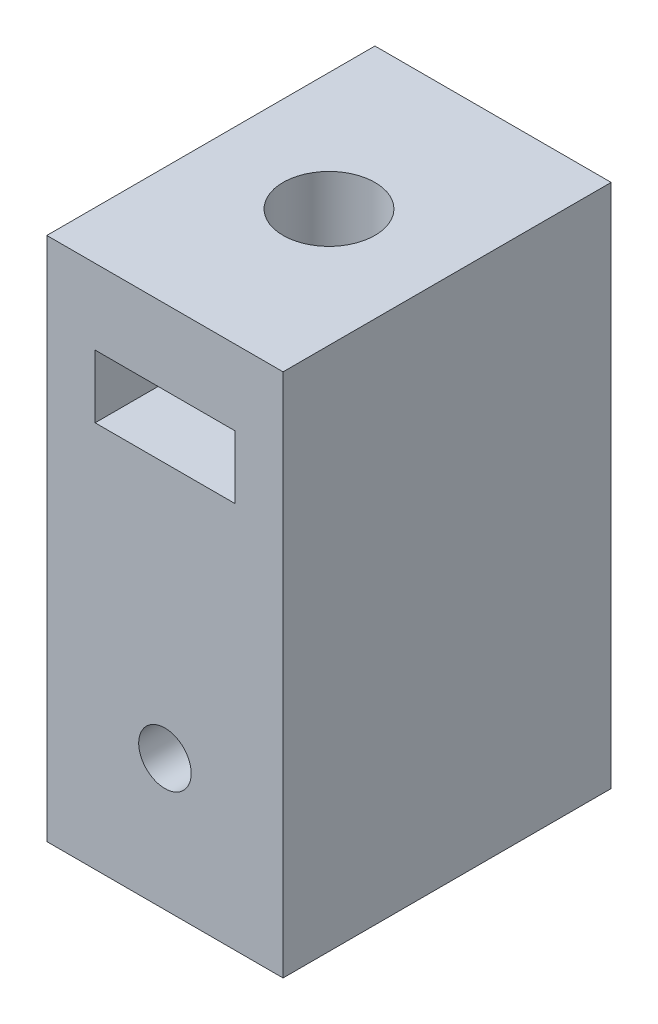
from build123d import *

# Parameters (mm, degrees)
SKETCH1_W           = 9
SKETCH1_H           = 12.5
BOSS_EXTRUDE1_DEPTH = 20
SKETCH2_R           = 1
CUT_EXTRUDE1_DEPTH  = 13.5
SKETCH3_W           = 5.32
SKETCH3_H           = 2.4
CUT_EXTRUDE2_DEPTH  = 13.5
SKETCH4_R           = 1.75
CUT_EXTRUDE3_DEPTH  = 13


with BuildPart() as part:
    # Sketch1 → Boss-Extrude1 (new body)
    with BuildSketch(Plane(origin=(0, 0, 0), x_dir=(1, 0, 0), z_dir=(0, 1, 0))):
        Rectangle(SKETCH1_W, SKETCH1_H)
    extrude(amount=BOSS_EXTRUDE1_DEPTH)

    # Sketch2 → Cut-Extrude1 (cut, through all)
    with BuildSketch(Plane.XY.offset(6.25)):
        with Locations((0, 5)):
            Circle(SKETCH2_R)
    extrude(amount=-CUT_EXTRUDE1_DEPTH, mode=Mode.SUBTRACT)

    # Sketch3 → Cut-Extrude2 (cut, through all)
    with BuildSketch(Plane.XY.offset(6.25)):
        with Locations((0, 15.93763485)):
            Rectangle(SKETCH3_W, SKETCH3_H)
    extrude(amount=-CUT_EXTRUDE2_DEPTH, mode=Mode.SUBTRACT)

    # Sketch4 → Cut-Extrude3 (cut)
    with BuildSketch(Plane(origin=(0, 20, 0), x_dir=(1, 0, 0), z_dir=(0, 1, 0))):
        Circle(SKETCH4_R)
    extrude(amount=-CUT_EXTRUDE3_DEPTH, mode=Mode.SUBTRACT)


solid = part.part
